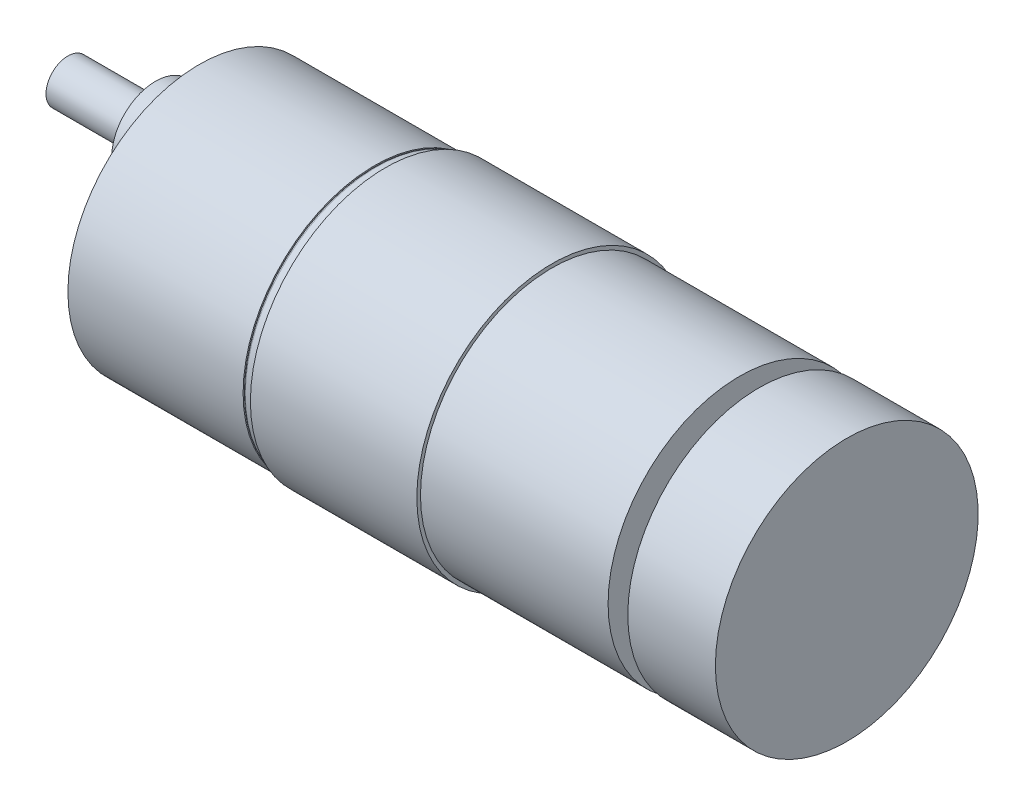
from build123d import *

# Parameters (mm, degrees)
SKETCH_6_R           = 6
EXTRUDE_3_DEPTH      = 6
SKETCH_7_R           = 3
EXTRUDE_4_DEPTH      = 12
SKETCH_8_R           = 1.5
CUT_EXTRUDE_22_DEPTH = 12


with BuildPart() as part:
    # 草图5 → 旋转1 (revolve)
    with BuildSketch(Plane.XY):
        with BuildLine():
            Line((0, 0), (0, 18))
            Line((0, 18), (24, 18))
            Line((24, 18), (24, 17.7))
            ThreePointArc((24, 17.7), (24.087867966, 17.912132034), (24.3, 18))
            Line((24.3, 18), (25.5, 18))
            Line((25.5, 18), (25.5, 18.5))
            Line((25.5, 18.5), (48.3, 18.5))
            Line((48.3, 18.5), (48.3, 18))
            Line((48.3, 18), (74, 18))
            Line((74, 18), (74, 6))
            Line((74, 6), (76.7, 6))
            Line((76.7, 6), (76.7, 18))
            Line((76.7, 18), (88.7, 18))
            Line((88.7, 18), (88.7, 0))
            Line((88.7, 0), (0, 0))
        make_face()
    revolve(axis=Axis((-65.679090957, 0, 0), (1, 0, 0)))

    # 草图6 → 凸台-拉伸3 (add)
    with BuildSketch(Plane.ZY):
        with Locations((0, 7)):
            Circle(SKETCH_6_R)
    extrude(amount=EXTRUDE_3_DEPTH)

    # 草图7 → 凸台-拉伸4 (add)
    with BuildSketch(Plane.ZY.offset(6)):
        with Locations((0, 7)):
            Circle(SKETCH_7_R)
    extrude(amount=EXTRUDE_4_DEPTH)

    # 草图8 → 切除-拉伸22 (cut)
    with BuildSketch(Plane.ZY):
        with Locations((15.5, 0)):
            Circle(SKETCH_8_R)
        with Locations((7.75, -13.423393759)):
            Circle(SKETCH_8_R)
        with Locations((-7.75, -13.423393759)):
            Circle(SKETCH_8_R)
        with Locations((-15.5, 0)):
            Circle(SKETCH_8_R)
        with Locations((-7.75, 13.423393759)):
            Circle(SKETCH_8_R)
        with Locations((7.75, 13.423393759)):
            Circle(SKETCH_8_R)
    extrude(amount=-CUT_EXTRUDE_22_DEPTH, mode=Mode.SUBTRACT)


solid = part.part
